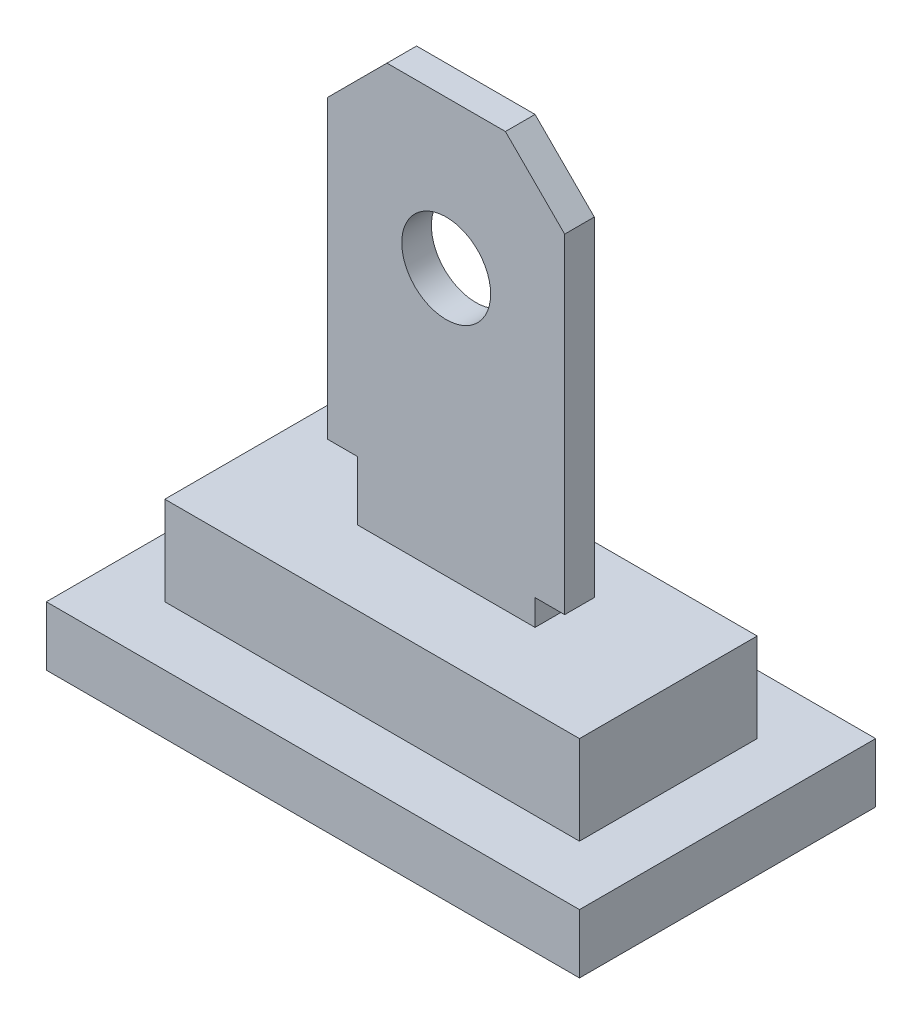
from build123d import *

# Parameters (mm, degrees)
SKETCH1_W           = 7
SKETCH1_H           = 3
BOSS_EXTRUDE1_DEPTH = 1.5
SKETCH2_W           = 9
SKETCH2_H           = 5
BOSS_EXTRUDE2_DEPTH = 1
SKETCH3_R           = 0.75
BOSS_EXTRUDE3_DEPTH = 0.25


with BuildPart() as part:
    # Sketch1 → Boss-Extrude1 (new body)
    with BuildSketch(Plane(origin=(0, 0, 0), x_dir=(1, 0, 0), z_dir=(0, 1, 0))):
        Rectangle(SKETCH1_W, SKETCH1_H)
    extrude(amount=BOSS_EXTRUDE1_DEPTH)

    # Sketch2 → Boss-Extrude2 (add)
    with BuildSketch(Plane.XZ):
        Rectangle(SKETCH2_W, SKETCH2_H)
    extrude(amount=BOSS_EXTRUDE2_DEPTH)

    # Sketch3 → Boss-Extrude3 (add, symmetric)
    with BuildSketch(Plane.XY):
        Polygon((-1.5, 1.5), (-1.5, 2.5), (-2, 2.5), (-2, 7.5), (-1, 8.5), (1, 8.5), (2, 7.5), (2, 1.936391511), (1.5, 1.936391511), (1.5, 1.5), align=None)
        with Locations((0, 6)):
            Circle(SKETCH3_R, mode=Mode.SUBTRACT)
    extrude(amount=BOSS_EXTRUDE3_DEPTH, both=True)


solid = part.part
